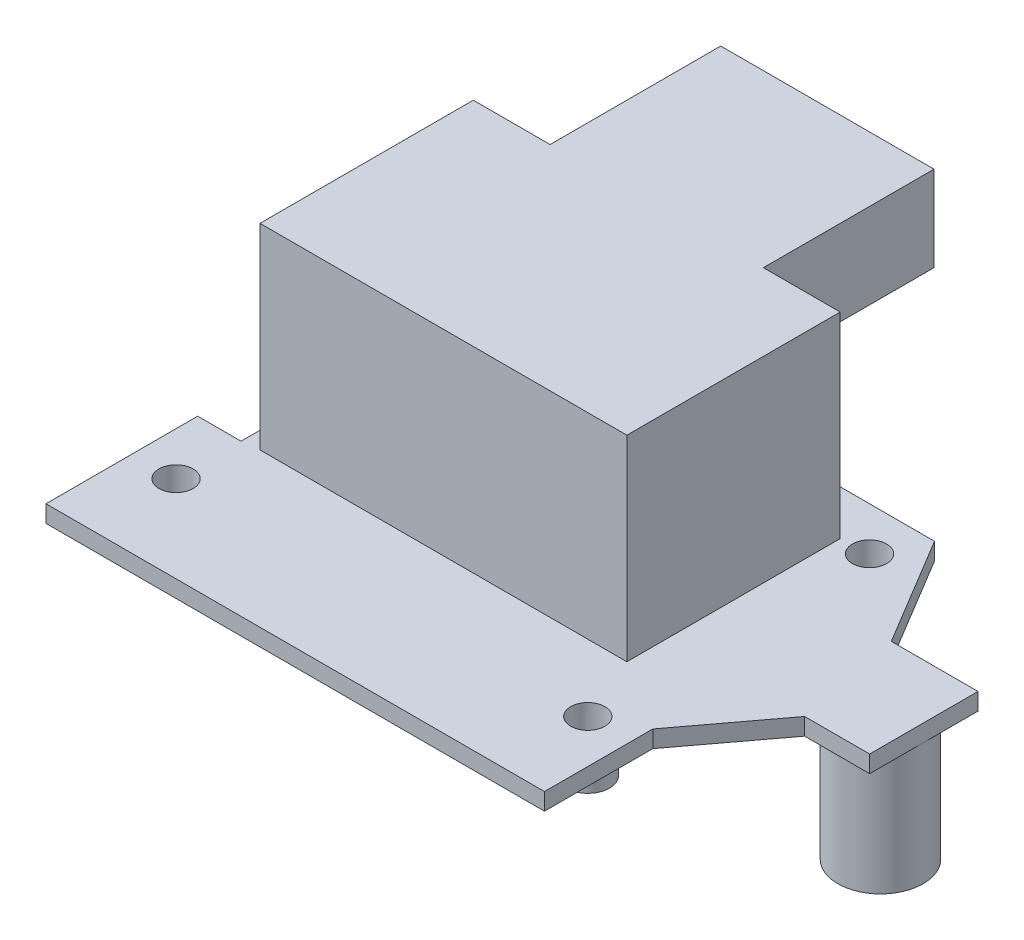
from build123d import *

# Parameters (mm, degrees)
SKETCH1_R           = 2
BOSS_EXTRUDE1_DEPTH = 2
SKETCH2_W           = 43
SKETCH2_H           = 25
BOSS_EXTRUDE2_DEPTH = 23
SKETCH4_R           = 5
BOSS_EXTRUDE3_DEPTH = 14.39
SKETCH5_R           = 2.555
SKETCH5_R_2         = 2
BOSS_EXTRUDE4_DEPTH = 4
SKETCH6_W           = 25
SKETCH6_H           = 10
BOSS_EXTRUDE5_DEPTH = 20


with BuildPart() as part:
    # Sketch1 → Boss-Extrude1 (new body)
    with BuildSketch(Plane(origin=(0, 0, 0), x_dir=(1, 0, 0), z_dir=(0, 1, 0))):
        Polygon((55.88, 48.26), (63.507713889, 35.565352277), (73.667713889, 35.565352277), (73.667713889, 22.865352277), (66.047713889, 22.865352277), (58.42, 12.7), (58.42, 0), (0, 0), (0, 17.78), (5.08, 17.78), (5.08, 48.26), align=None)
        with Locations((5.08, 10.16)):
            Circle(SKETCH1_R, mode=Mode.SUBTRACT)
        with Locations((53.34, 10.16)):
            Circle(SKETCH1_R, mode=Mode.SUBTRACT)
        with Locations((53.34, 43.18)):
            Circle(SKETCH1_R, mode=Mode.SUBTRACT)
    extrude(amount=BOSS_EXTRUDE1_DEPTH)

    # Sketch2 → Boss-Extrude2 (add)
    with BuildSketch(Plane(origin=(0, 2, 0), x_dir=(1, 0, 0), z_dir=(0, 1, 0))):
        with Locations((28.58, 30.5)):
            Rectangle(SKETCH2_W, SKETCH2_H)
    extrude(amount=BOSS_EXTRUDE2_DEPTH)

    # Sketch4 → Boss-Extrude3 (add)
    with BuildSketch(Plane.XZ):
        with Locations((68.587713889, -29.215352277)):
            Circle(SKETCH4_R)
    extrude(amount=BOSS_EXTRUDE3_DEPTH)

    # Sketch5 → Boss-Extrude4 (add)
    with BuildSketch(Plane.XZ):
        with Locations((5.08, -10.16)):
            Circle(SKETCH5_R)
        with Locations((5.08, -10.16)):
            Circle(SKETCH5_R_2, mode=Mode.SUBTRACT)
        with Locations((53.34, -10.16)):
            Circle(SKETCH5_R)
        with Locations((53.34, -10.16)):
            Circle(SKETCH5_R_2, mode=Mode.SUBTRACT)
        with Locations((53.34, -43.18)):
            Circle(SKETCH5_R)
        with Locations((53.34, -43.18)):
            Circle(SKETCH5_R_2, mode=Mode.SUBTRACT)
    extrude(amount=BOSS_EXTRUDE4_DEPTH)

    # Sketch6 → Boss-Extrude5 (add)
    with BuildSketch(Plane(origin=(0, 0, -43), x_dir=(-1, 0, 0), z_dir=(0, 0, -1))):
        with Locations((-28.58, 20)):
            Rectangle(SKETCH6_W, SKETCH6_H)
    extrude(amount=BOSS_EXTRUDE5_DEPTH)


solid = part.part
